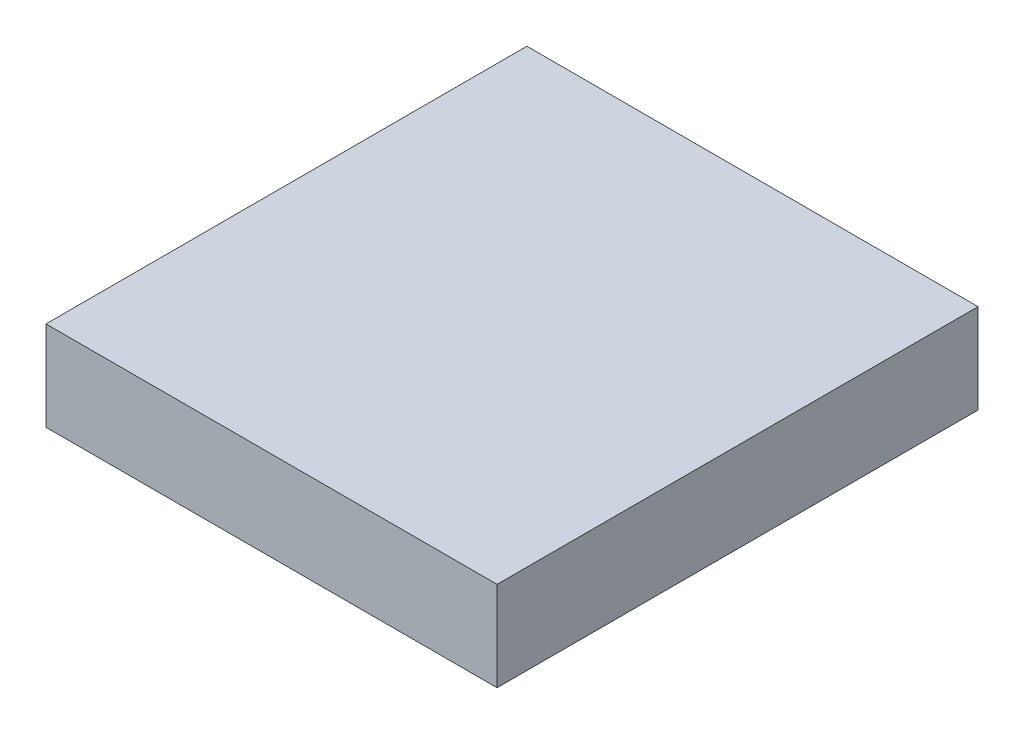
from build123d import *

# Parameters (mm, degrees)
SKETCH1_W           = 431.8
SKETCH1_H           = 460.375
BOSS_EXTRUDE1_DEPTH = 85.725


with BuildPart() as part:
    # Sketch1 → Boss-Extrude1 (new body)
    with BuildSketch(Plane(origin=(0, 0, 0), x_dir=(1, 0, 0), z_dir=(0, 1, 0))):
        Rectangle(SKETCH1_W, SKETCH1_H)
    extrude(amount=BOSS_EXTRUDE1_DEPTH)


solid = part.part
